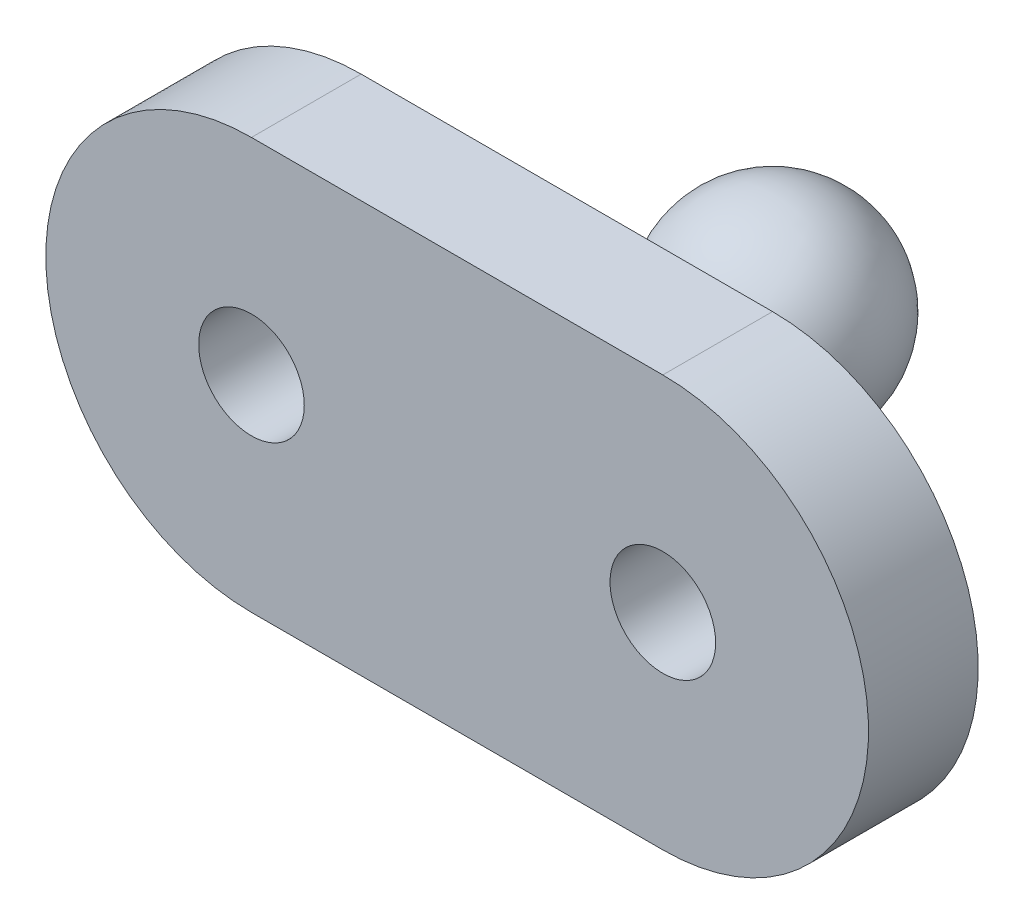
from build123d import *

# Parameters (mm, degrees)
SKETCH1_R           = 1.925
BOSS_EXTRUDE1_DEPTH = 4
FILLET1_R           = 3


with BuildPart() as part:
    # Sketch1 → Boss-Extrude1 (new body)
    with BuildSketch(Plane.XY):
        with BuildLine():
            Line((-7.5, 7.5), (7.5, 7.5))
            ThreePointArc((7.5, 7.5), (15, 0), (7.5, -7.5))
            Line((7.5, -7.5), (-7.5, -7.5))
            ThreePointArc((-7.5, -7.5), (-15, 0), (-7.5, 7.5))
        make_face()
        with Locations((7.5, 0)):
            Circle(SKETCH1_R, mode=Mode.SUBTRACT)
        with Locations((-7.5, 0)):
            Circle(SKETCH1_R, mode=Mode.SUBTRACT)
    extrude(amount=BOSS_EXTRUDE1_DEPTH)

    # Sketch3 → Revolve1 (revolve)
    with BuildSketch(Plane(origin=(0, 0, 0), x_dir=(1, 0, 0), z_dir=(0, 1, 0))):
        with BuildLine():
            Line((0, 11.25), (0, 7.5))
            Line((0, 7.5), (1.75, 7.5))
            Line((1.75, 7.5), (2.063144305, 4.36855695))
            ThreePointArc((2.063144305, 4.36855695), (3.592033647, 8.576937454), (0, 11.25))
        make_face()
        with BuildLine():
            Line((1.75, 7.5), (0, 7.5))
            Line((0, 7.5), (0, 3.75))
            ThreePointArc((0, 3.75), (1.076937454, 3.907966353), (2.063144305, 4.36855695))
            Line((2.063144305, 4.36855695), (1.75, 7.5))
        make_face()
        with BuildLine():
            ThreePointArc((2.063144305, 4.36855695), (1.076937454, 3.907966353), (0, 3.75))
            Line((0, 3.75), (0, 0))
            Line((0, 0), (2.5, 0))
            Line((2.5, 0), (2.063144305, 4.36855695))
        make_face()
    revolve(axis=Axis((0, 0, 0), (0, 0, -1)))

    # Fillet1
    fillet1_edges = [part.edges().sort_by_distance(p)[0] for p in [
        (-2.5, 0, 0),
    ]]
    fillet(fillet1_edges, radius=FILLET1_R)


solid = part.part
